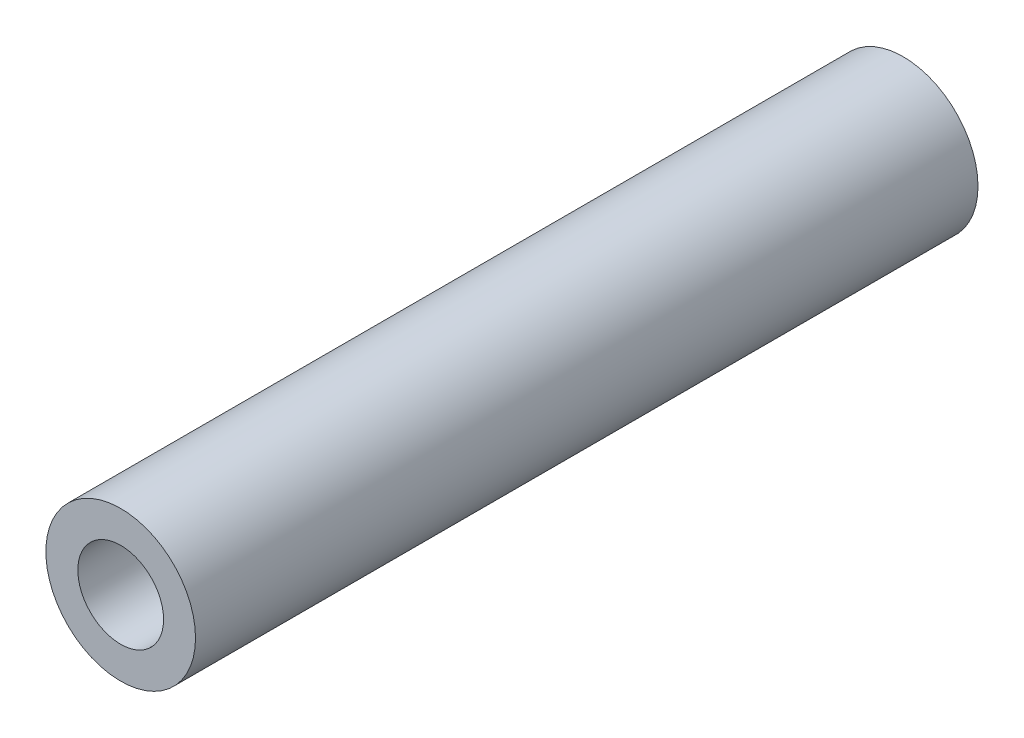
from build123d import *

# Parameters (mm, degrees)
SKETCH1_R           = 2.4384
SKETCH1_R_2         = 1.397
BOSS_EXTRUDE1_DEPTH = 25.49906


with BuildPart() as part:
    # Sketch1 → Boss-Extrude1 (new body)
    with BuildSketch(Plane.XY):
        Circle(SKETCH1_R)
        Circle(SKETCH1_R_2, mode=Mode.SUBTRACT)
    extrude(amount=BOSS_EXTRUDE1_DEPTH)


solid = part.part
